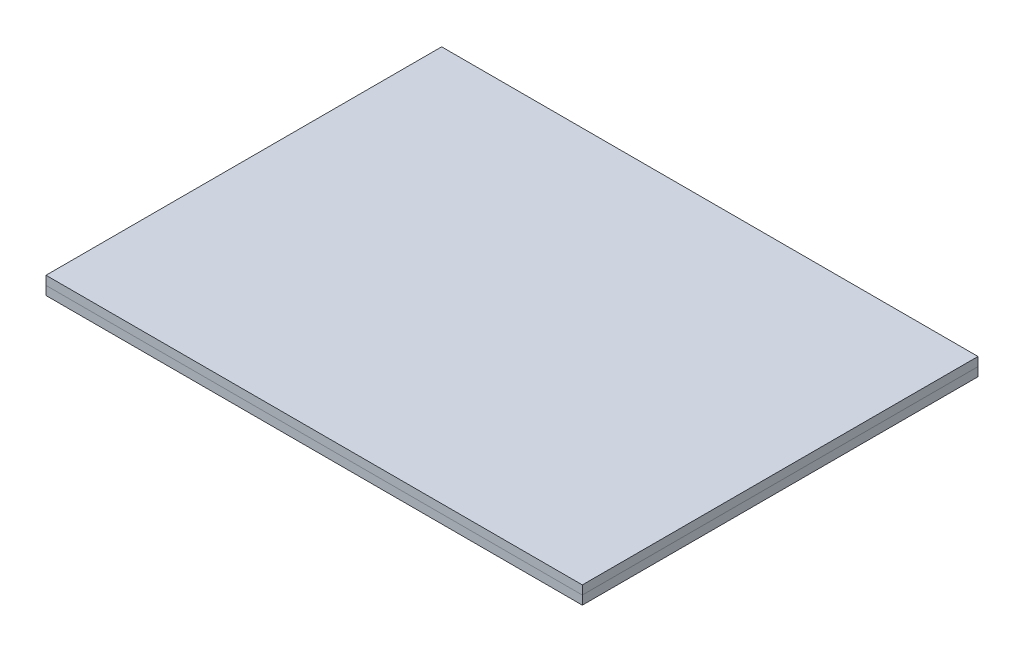
from build123d import *

# Parameters (mm, degrees)
SKETCH1_W           = 61
SKETCH1_H           = 45
BOSS_EXTRUDE1_DEPTH = 1
BOSS_EXTRUDE3_START = 1
SKETCH1_3_W         = 61
SKETCH1_3_H         = 45
BOSS_EXTRUDE3_DEPTH = 1


with BuildPart() as part:
    # Sketch1 → Boss-Extrude1 (new body)
    with BuildSketch(Plane(origin=(0, 0, 0), x_dir=(1, 0, 0), z_dir=(0, 1, 0))):
        with Locations((2.931492843, -7.40593047)):
            Rectangle(SKETCH1_W, SKETCH1_H)
    extrude(amount=BOSS_EXTRUDE1_DEPTH)


with BuildPart() as body_2:
    # Sketch1_3 → Boss-Extrude3 (new body)
    with BuildSketch(Plane(origin=(0, 0, 0), x_dir=(1, 0, 0), z_dir=(0, 1, 0)).offset(BOSS_EXTRUDE3_START)):
        with Locations((2.931492843, -7.40593047)):
            Rectangle(SKETCH1_3_W, SKETCH1_3_H)
    extrude(amount=BOSS_EXTRUDE3_DEPTH)


solid = Compound([part.part, body_2.part])
